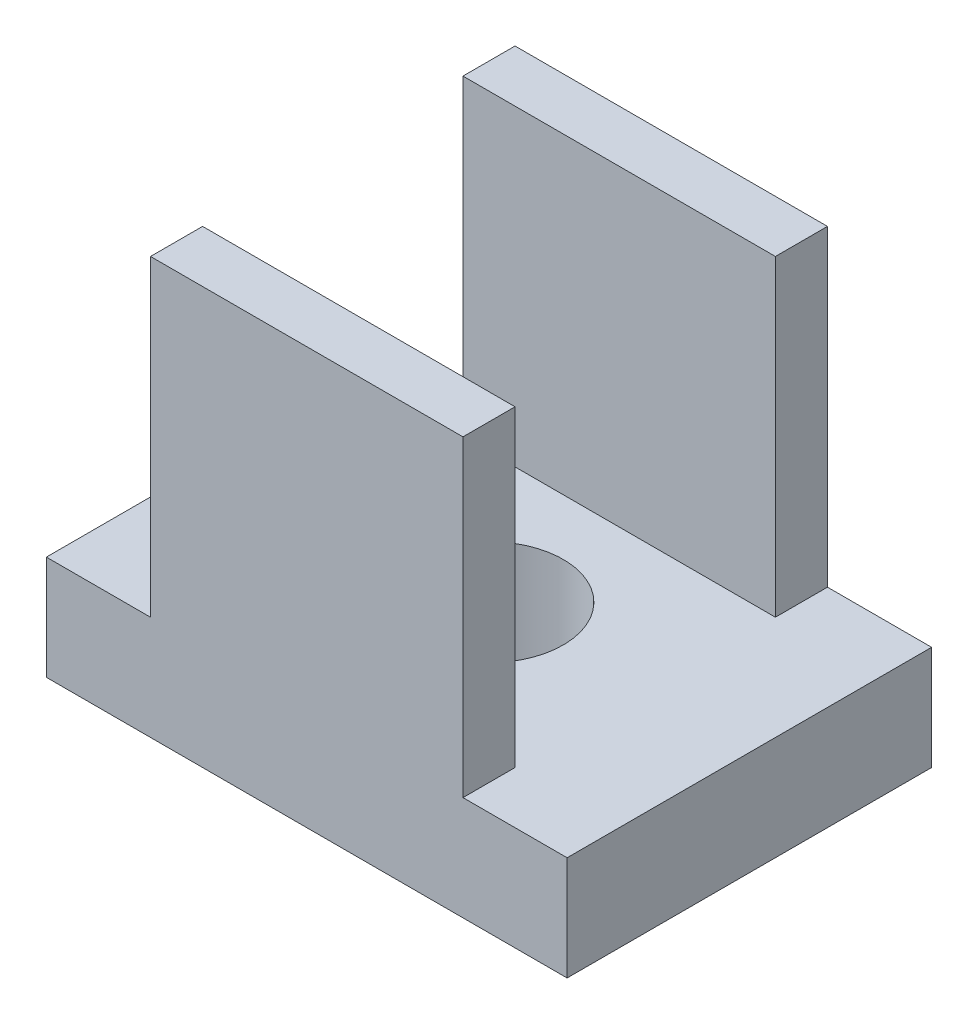
from build123d import *

# Parameters (mm, degrees)
SKETCH1_W           = 10
SKETCH1_H           = 7
BOSS_EXTRUDE1_DEPTH = 2
SKETCH2_R           = 1.425
CUT_EXTRUDE1_DEPTH  = 2
SKETCH3_W           = 6
SKETCH3_H           = 1
BOSS_EXTRUDE2_DEPTH = 6


with BuildPart() as part:
    # Sketch1 → Boss-Extrude1 (new body)
    with BuildSketch(Plane(origin=(0, 0, 0), x_dir=(1, 0, 0), z_dir=(0, 1, 0))):
        Rectangle(SKETCH1_W, SKETCH1_H)
    extrude(amount=BOSS_EXTRUDE1_DEPTH)

    # Sketch2 → Cut-Extrude1 (cut)
    with BuildSketch(Plane(origin=(0, 2, 0), x_dir=(1, 0, 0), z_dir=(0, 1, 0))):
        Circle(SKETCH2_R)
    extrude(amount=-CUT_EXTRUDE1_DEPTH, mode=Mode.SUBTRACT)

    # Sketch3 → Boss-Extrude2 (add)
    with BuildSketch(Plane(origin=(0, 2, 0), x_dir=(1, 0, 0), z_dir=(0, 1, 0))):
        with Locations((0, -3)):
            Rectangle(SKETCH3_W, SKETCH3_H)
    boss_extrude2 = extrude(amount=BOSS_EXTRUDE2_DEPTH)

    # Mirror1: Boss-Extrude2 across plane
    add(boss_extrude2.mirror(Plane.XY))


solid = part.part
